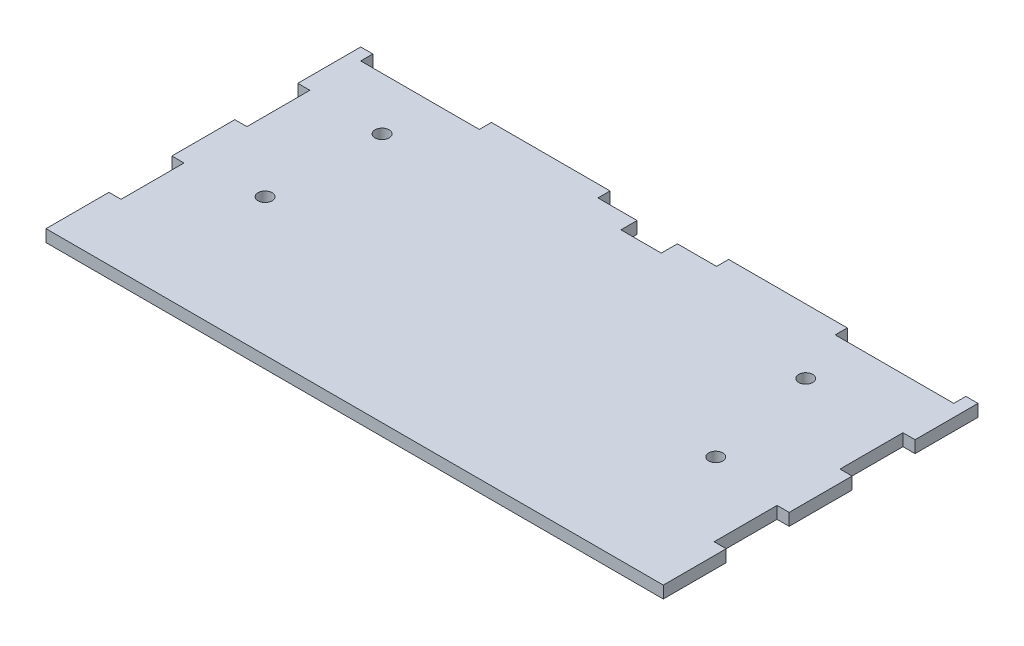
from build123d import *

# Parameters (mm, degrees)
SKETCH1_R           = 1.75
BOSS_EXTRUDE1_DEPTH = 3


with BuildPart() as part:
    # Sketch1 → Boss-Extrude1 (new body)
    with BuildSketch(Plane(origin=(0, 0, 0), x_dir=(1, 0, 0), z_dir=(0, 1, 0))):
        Polygon((-73.5, 33), (-44.1, 33), (-44.1, 36), (-14.7, 36), (-14.7, 33), (-5, 33), (-5, 32), (-5, 29), (0, 29), (5, 29), (5, 33), (14.7, 33), (14.7, 36), (44.1, 36), (44.1, 33), (73.5, 33), (73.5, 36), (76.5, 36), (76.5, 20.4), (73.5, 20.4), (73.5, 4.8), (76.5, 4.8), (76.5, -10.8), (73.5, -10.8), (73.5, -26.4), (76.5, -26.4), (76.5, -42), (-76.5, -42), (-76.5, -26.4), (-73.5, -26.4), (-73.5, -10.8), (-76.5, -10.8), (-76.5, 4.8), (-73.5, 4.8), (-73.5, 20.4), (-76.5, 20.4), (-76.5, 36), (-73.5, 36), align=None)
        with Locations((-56.2, -8)):
            Circle(SKETCH1_R, mode=Mode.SUBTRACT)
        with Locations((-55.2, 20)):
            Circle(SKETCH1_R, mode=Mode.SUBTRACT)
        with Locations((49.8, 20)):
            Circle(SKETCH1_R, mode=Mode.SUBTRACT)
        with Locations((55.5, -8)):
            Circle(SKETCH1_R, mode=Mode.SUBTRACT)
    extrude(amount=BOSS_EXTRUDE1_DEPTH)


solid = part.part
